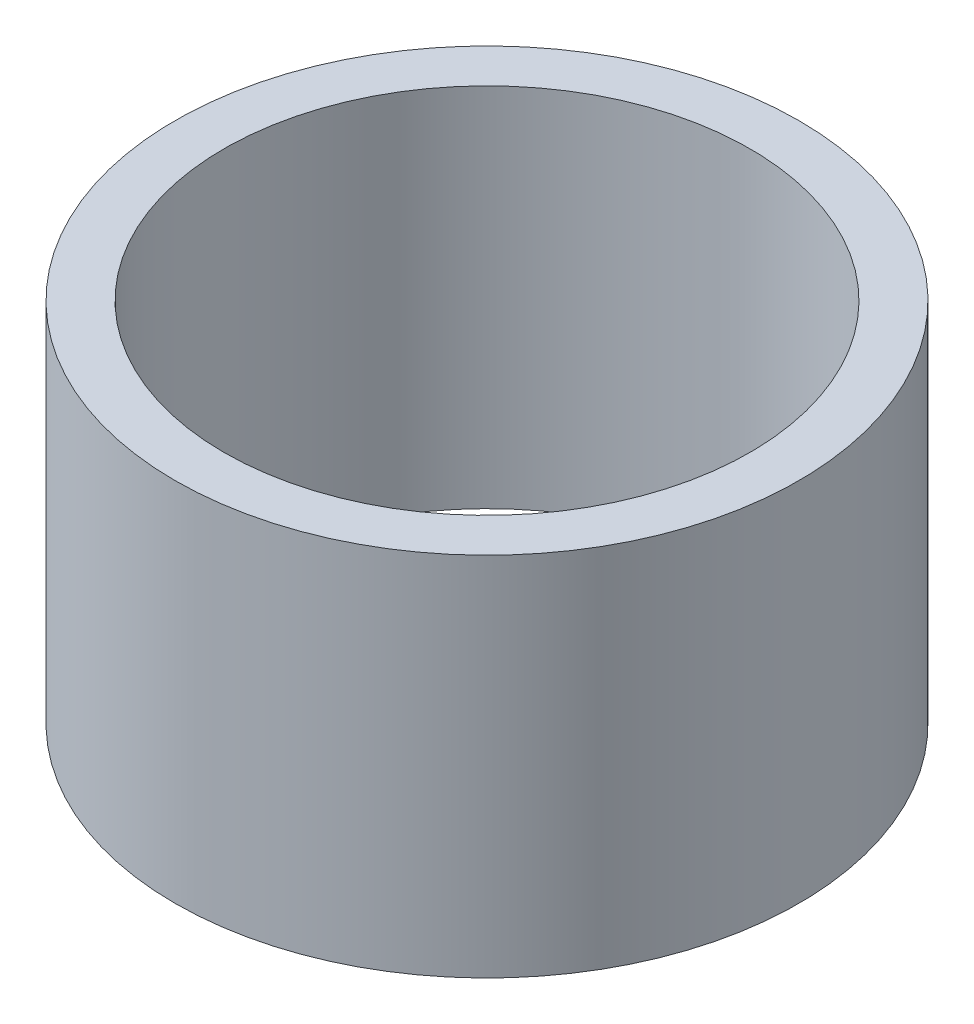
from build123d import *

# Parameters (mm, degrees)
SKETCH1_R           = 32.4485
SKETCH1_R_2         = 27.3685
BOSS_EXTRUDE1_DEPTH = 38.1


with BuildPart() as part:
    # Sketch1 → Boss-Extrude1 (new body)
    with BuildSketch(Plane(origin=(0, 0, 0), x_dir=(1, 0, 0), z_dir=(0, 1, 0))):
        Circle(SKETCH1_R)
        Circle(SKETCH1_R_2, mode=Mode.SUBTRACT)
    extrude(amount=BOSS_EXTRUDE1_DEPTH)


solid = part.part
